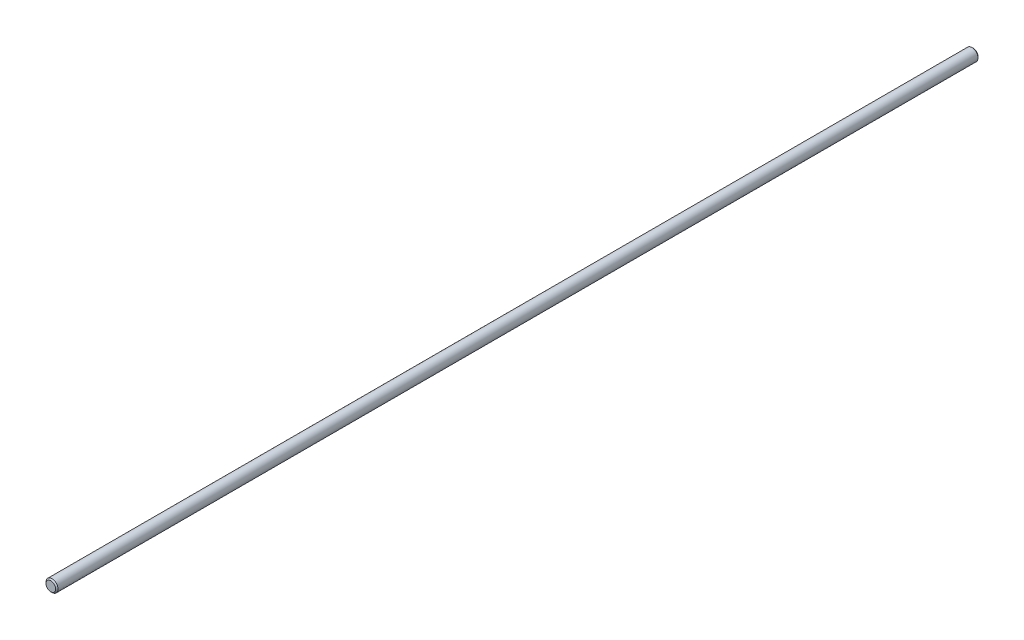
from build123d import *

# Parameters (mm, degrees)
SKETCH3_R           = 3.96875
BOSS_EXTRUDE1_DEPTH = 304.8
CHAMFER1_SIZE       = 0.79375


with BuildPart() as part:
    # Sketch3 → Boss-Extrude1 (new body, symmetric)
    with BuildSketch(Plane.XY):
        Circle(SKETCH3_R)
    extrude(amount=BOSS_EXTRUDE1_DEPTH, both=True)

    # Chamfer1
    chamfer1_edges = [part.edges().sort_by_distance(p)[0] for p in [
        (-3.96875, 0, -304.8),
        (-3.96875, 0, 304.8),
    ]]
    chamfer(chamfer1_edges, length=CHAMFER1_SIZE)


solid = part.part
